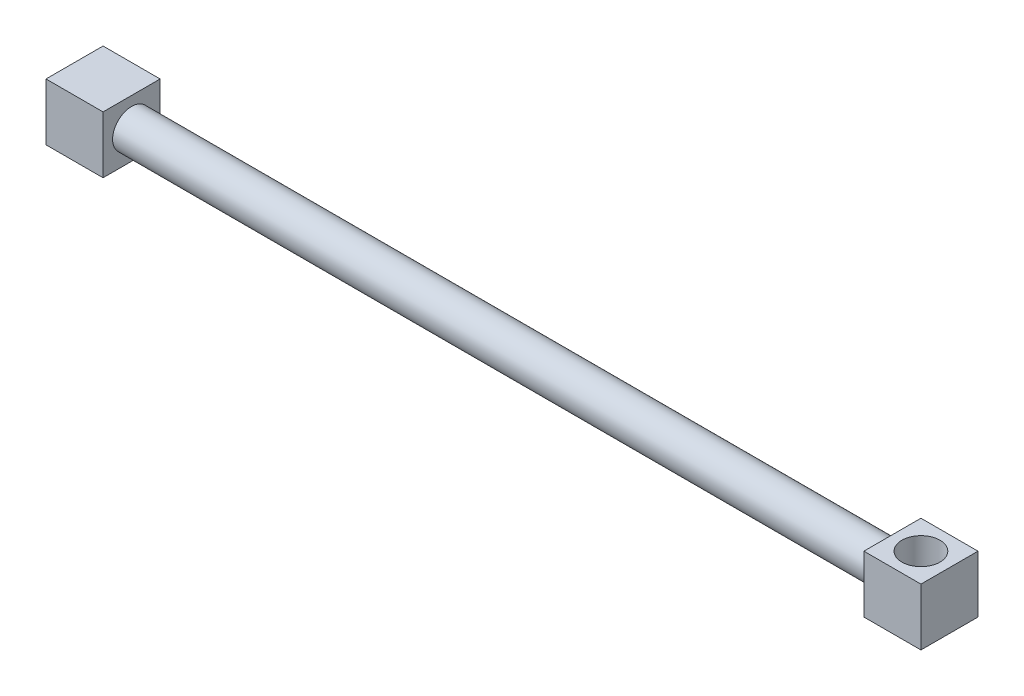
from build123d import *

# Parameters (mm, degrees)
SKETCH1_W           = 30
SKETCH1_H           = 30
BOSS_EXTRUDE1_DEPTH = 30
SKETCH2_R           = 10
BOSS_EXTRUDE2_DEPTH = 400
SKETCH3_W           = 30
SKETCH3_H           = 30
BOSS_EXTRUDE3_DEPTH = 30
SKETCH4_R           = 10
CUT_EXTRUDE1_DEPTH  = 30


with BuildPart() as part:
    # Sketch1 → Boss-Extrude1 (new body)
    with BuildSketch(Plane(origin=(0, 0, 0), x_dir=(0, 0, -1), z_dir=(1, 0, 0))):
        Rectangle(SKETCH1_W, SKETCH1_H)
    extrude(amount=BOSS_EXTRUDE1_DEPTH)

    # Sketch2 → Boss-Extrude2 (add)
    with BuildSketch(Plane(origin=(30, 0, 0), x_dir=(0, 0, -1), z_dir=(1, 0, 0))):
        Circle(SKETCH2_R)
    extrude(amount=BOSS_EXTRUDE2_DEPTH)

    # Sketch3 → Boss-Extrude3 (add)
    with BuildSketch(Plane(origin=(430, 0, 0), x_dir=(0, 0, -1), z_dir=(1, 0, 0))):
        Rectangle(SKETCH3_W, SKETCH3_H)
    extrude(amount=BOSS_EXTRUDE3_DEPTH)

    # Sketch4 → Cut-Extrude1 (cut)
    with BuildSketch(Plane(origin=(0, 15, 0), x_dir=(1, 0, 0), z_dir=(0, 1, 0))):
        with Locations((445, 0)):
            Circle(SKETCH4_R)
    extrude(amount=-CUT_EXTRUDE1_DEPTH, mode=Mode.SUBTRACT)


solid = part.part
